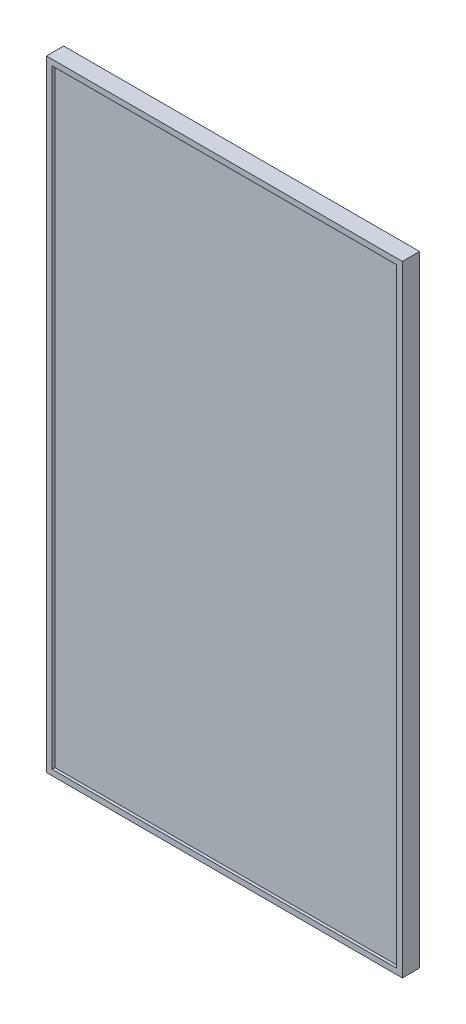
from build123d import *

# Parameters (mm, degrees)
SKETCH1_W           = 629.1
SKETCH1_H           = 1096.9
BOSS_EXTRUDE1_DEPTH = 30.5
SKETCH2_R           = 4
CUT_EXTRUDE1_DEPTH  = 21
SKETCH3_W           = 609.1
SKETCH3_H           = 1076.9
CUT_EXTRUDE2_DEPTH  = 5


with BuildPart() as part:
    # Sketch1 → Boss-Extrude1 (new body)
    with BuildSketch(Plane.XY):
        Rectangle(SKETCH1_W, SKETCH1_H)
    extrude(amount=BOSS_EXTRUDE1_DEPTH)

    # Sketch2 → Cut-Extrude1 (cut)
    with BuildSketch(Plane(origin=(0, 0, 0), x_dir=(-1, 0, 0), z_dir=(0, 0, -1))):
        with Locations((-200, 200)):
            Circle(SKETCH2_R)
        with Locations((200, 200)):
            Circle(SKETCH2_R)
        with Locations((200, -200)):
            Circle(SKETCH2_R)
        with Locations((-200, -200)):
            Circle(SKETCH2_R)
    extrude(amount=-CUT_EXTRUDE1_DEPTH, mode=Mode.SUBTRACT)

    # Sketch3 → Cut-Extrude2 (cut)
    with BuildSketch(Plane.XY.offset(30.5)):
        Rectangle(SKETCH3_W, SKETCH3_H)
    extrude(amount=-CUT_EXTRUDE2_DEPTH, mode=Mode.SUBTRACT)


solid = part.part
